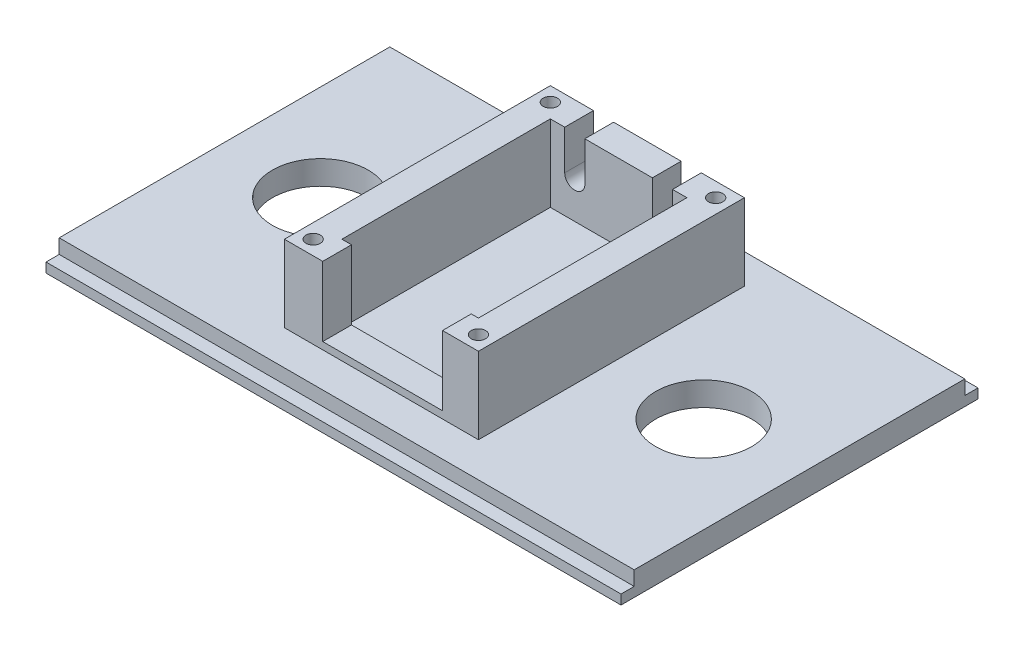
from build123d import *

# Parameters (mm, degrees)
SKETCH1_W               = 120
SKETCH1_H               = 74.5
BOSS_EXTRUDE1_DEPTH     = 2
SKETCH2_W               = 120
SKETCH2_H               = 69
BOSS_EXTRUDE2_DEPTH     = 3
SKETCH3_W               = 40.5
SKETCH3_H               = 55.5
SKETCH3_W_2             = 28.5
SKETCH3_H_2             = 43.5
BOSS_EXTRUDE3_DEPTH     = 16
SKETCH4_W               = 25
SKETCH4_H               = 14.5
CUT_EXTRUDE1_DEPTH      = 16
CUT_EXTRUDE2_DEPTH      = 16
SKETCH6_R               = 1.5
CUT_EXTRUDE3_DEPTH      = 10
SKETCH7_R               = 10
CUT_EXTRUDE4_DEPTH      = 17
CUT_EXTRUDE4_DEPTH_BACK = 6


with BuildPart() as part:
    # Sketch1 → Boss-Extrude1 (new body)
    with BuildSketch(Plane(origin=(0, 0, 0), x_dir=(1, 0, 0), z_dir=(0, 1, 0))):
        Rectangle(SKETCH1_W, SKETCH1_H)
    extrude(amount=BOSS_EXTRUDE1_DEPTH)

    # Sketch2 → Boss-Extrude2 (add)
    with BuildSketch(Plane(origin=(0, 2, 0), x_dir=(1, 0, 0), z_dir=(0, 1, 0))):
        Rectangle(SKETCH2_W, SKETCH2_H)
    extrude(amount=BOSS_EXTRUDE2_DEPTH)

    # Sketch3 → Boss-Extrude3 (add)
    with BuildSketch(Plane(origin=(0, 5, 0), x_dir=(1, 0, 0), z_dir=(0, 1, 0))):
        with Locations((0, 0.5)):
            Rectangle(SKETCH3_W, SKETCH3_H)
        with Locations((0, 0.5)):
            Rectangle(SKETCH3_W_2, SKETCH3_H_2, mode=Mode.SUBTRACT)
    extrude(amount=BOSS_EXTRUDE3_DEPTH)

    # Sketch4 → Cut-Extrude1 (cut)
    with BuildSketch(Plane.XY.offset(27.25)):
        with Locations((0.25, 13.75)):
            Rectangle(SKETCH4_W, SKETCH4_H)
    extrude(amount=-CUT_EXTRUDE1_DEPTH, mode=Mode.SUBTRACT)

    # Sketch5 → Cut-Extrude2 (cut)
    with BuildSketch(Plane(origin=(0, 0, -28.25), x_dir=(-1, 0, 0), z_dir=(0, 0, -1))):
        with BuildLine():
            Line((-7.05, 21), (-11.25, 21))
            Line((-11.25, 21), (-11.25, 12.75))
            ThreePointArc((-11.25, 12.75), (-9.15, 14.85), (-7.05, 12.75))
            Line((-7.05, 12.75), (-7.05, 21))
        make_face()
        with BuildLine():
            ThreePointArc((-7.05, 12.75), (-9.15, 14.85), (-11.25, 12.75))
            Line((-11.25, 12.75), (-7.05, 12.75))
        make_face()
        with BuildLine():
            Line((-7.05, 12.75), (-11.25, 12.75))
            ThreePointArc((-11.25, 12.75), (-9.15, 10.65), (-7.05, 12.75))
        make_face()
        with BuildLine():
            ThreePointArc((11.25, 12.75), (9.15, 14.85), (7.05, 12.75))
            Line((7.05, 12.75), (11.25, 12.75))
        make_face()
        with BuildLine():
            Line((11.25, 12.75), (7.05, 12.75))
            ThreePointArc((7.05, 12.75), (9.15, 10.65), (11.25, 12.75))
        make_face()
        with BuildLine():
            Line((11.25, 21), (7.05, 21))
            Line((7.05, 21), (7.05, 12.75))
            ThreePointArc((7.05, 12.75), (9.15, 14.85), (11.25, 12.75))
            Line((11.25, 12.75), (11.25, 21))
        make_face()
    extrude(amount=-CUT_EXTRUDE2_DEPTH, mode=Mode.SUBTRACT)

    # Sketch6 → Cut-Extrude3 (cut)
    with BuildSketch(Plane(origin=(0, 21, 0), x_dir=(1, 0, 0), z_dir=(0, 1, 0))):
        with Locations((17.25, 25.25)):
            Circle(SKETCH6_R)
        with Locations((17.25, -24.25)):
            Circle(SKETCH6_R)
        with Locations((-17.25, -24.25)):
            Circle(SKETCH6_R)
        with Locations((-17.25, 25.25)):
            Circle(SKETCH6_R)
    extrude(amount=-CUT_EXTRUDE3_DEPTH, mode=Mode.SUBTRACT)

    # Sketch7 → Cut-Extrude4 (cut, two sides)
    with BuildSketch(Plane(origin=(0, 5, 0), x_dir=(1, 0, 0), z_dir=(0, 1, 0))) as cut_extrude4_sk:
        with Locations((-40, 0)):
            Circle(SKETCH7_R)
        with Locations((40, 0)):
            Circle(SKETCH7_R)
    extrude(amount=CUT_EXTRUDE4_DEPTH, mode=Mode.SUBTRACT)
    extrude(cut_extrude4_sk.sketch, amount=-CUT_EXTRUDE4_DEPTH_BACK, mode=Mode.SUBTRACT)


solid = part.part
